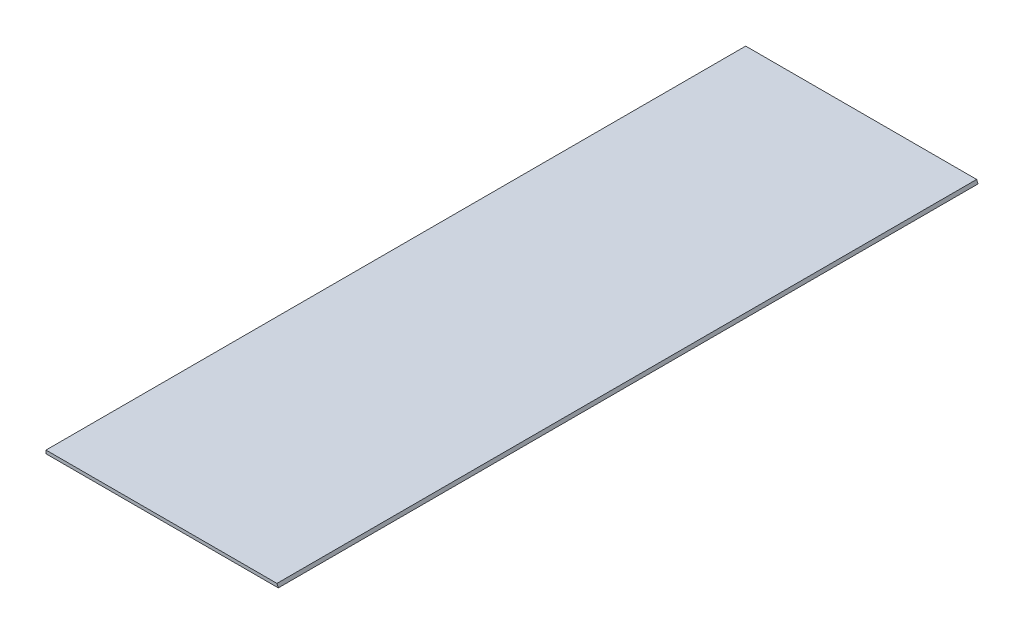
from build123d import *

# Parameters (mm, degrees)
BOSS_EXTRUDE1_DEPTH = 508


with BuildPart() as part:
    # Sketch1 → Boss-Extrude1 (new body)
    with BuildSketch(Plane.XY):
        Polygon((0, 0), (0, 2.3622), (167.677544723, 2.3622), (168.656, 0), align=None)
    extrude(amount=BOSS_EXTRUDE1_DEPTH)


solid = part.part
